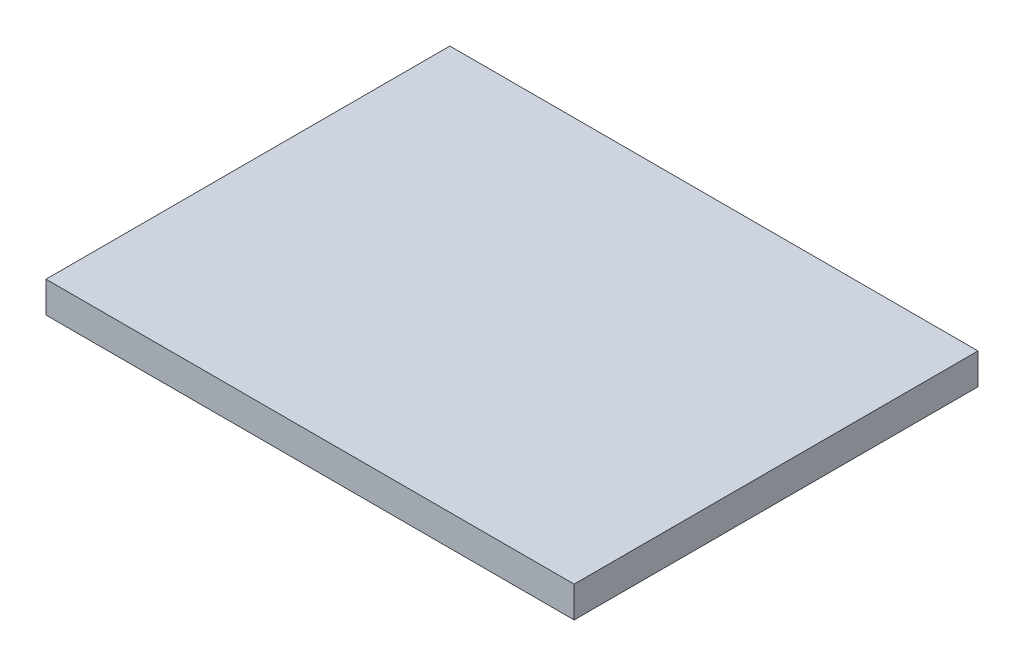
from build123d import *

# Parameters (mm, degrees)
CROQUIS1_W              = 85
CROQUIS1_H              = 65
SALIENTE_EXTRUIR1_DEPTH = 5


with BuildPart() as part:
    # Croquis1 → Saliente-Extruir1 (new body)
    with BuildSketch(Plane(origin=(0, 0, 0), x_dir=(1, 0, 0), z_dir=(0, 1, 0))):
        with Locations((1.63740458, 4.988549618)):
            Rectangle(CROQUIS1_W, CROQUIS1_H)
    extrude(amount=SALIENTE_EXTRUIR1_DEPTH)


solid = part.part
